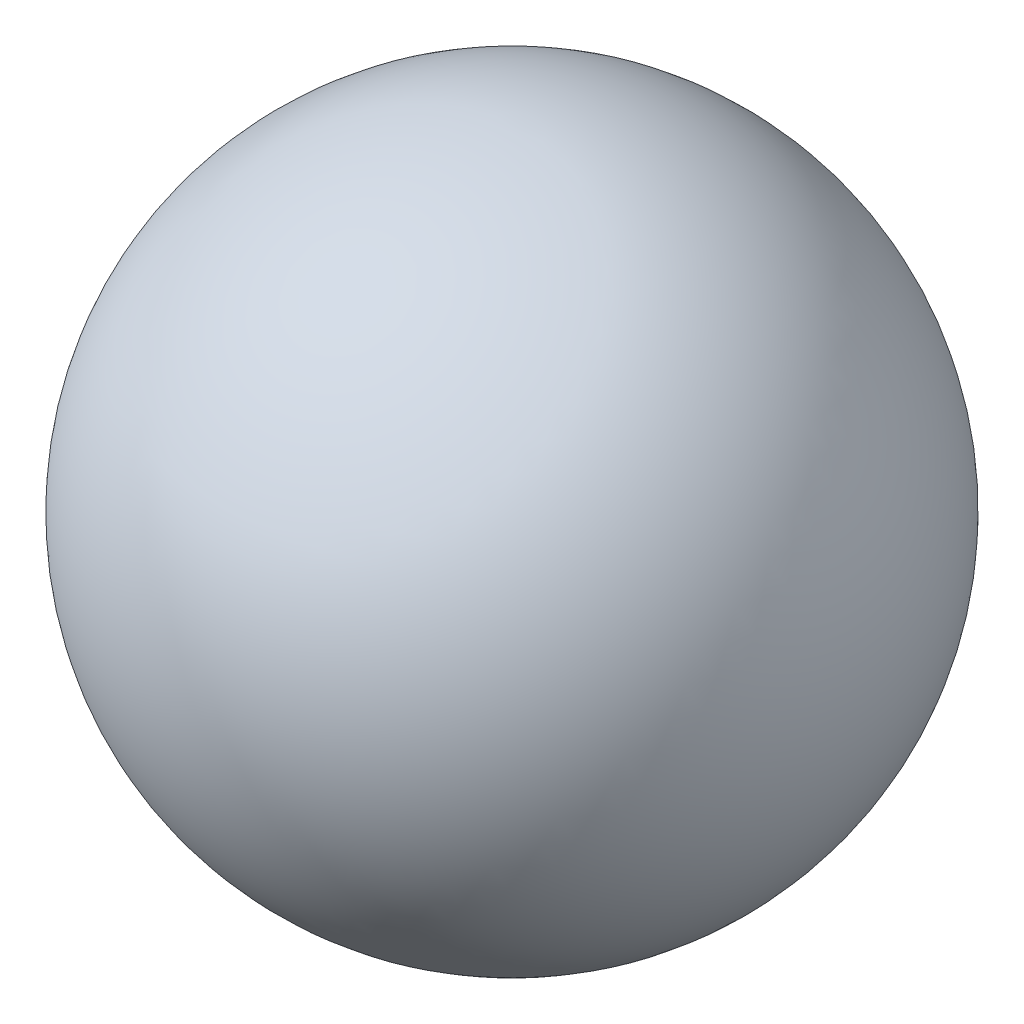
from build123d import *

# Parameters (mm, degrees)
F_1_16_0_0625_DIAMETER_HOLE1_D     = 1.569999908
F_1_16_0_0625_DIAMETER_HOLE1_DEPTH = 1.59
F_1_16_0_0625_DIAMETER_HOLE1_TIP   = 0.471675558


with BuildPart() as part:
    # Sketch1 → Revolve1 (revolve)
    with BuildSketch(Plane.XY):
        with BuildLine():
            Line((0, 1.5875), (0, -1.5875))
            ThreePointArc((0, -1.5875), (1.5875, 0), (0, 1.5875))
        make_face()
    revolve(axis=Axis((0, 48.640567602, 0), (0, -1, 0)))

    # 1/16 (0.0625) Diameter Hole1
    with Locations(Plane(origin=(0, -1.5875, 0), x_dir=(-1, 0, 0), z_dir=(0, -1, 0))):
        with Locations((0, 0)):
            Hole(F_1_16_0_0625_DIAMETER_HOLE1_D / 2, depth=F_1_16_0_0625_DIAMETER_HOLE1_DEPTH)
            with Locations((0, 0, -(F_1_16_0_0625_DIAMETER_HOLE1_DEPTH + F_1_16_0_0625_DIAMETER_HOLE1_TIP / 2))):  # 118° drill point
                Cone(0, F_1_16_0_0625_DIAMETER_HOLE1_D / 2, F_1_16_0_0625_DIAMETER_HOLE1_TIP, mode=Mode.SUBTRACT)


solid = part.part
